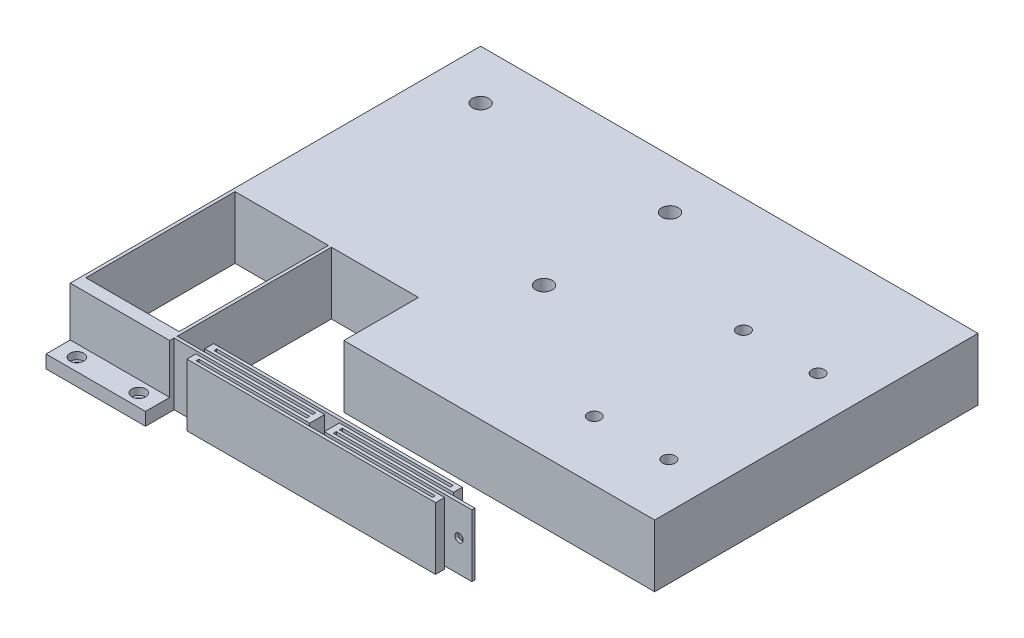
from build123d import *

# Parameters (mm, degrees)
SKETCH1_W                                      = 200
SKETCH1_H                                      = 174.75
BOSS_EXTRUDE1_DEPTH                            = 25
SKETCH2_W                                      = 40
SKETCH2_H                                      = 9.75
CUT_EXTRUDE1_DEPTH                             = 19.8
SKETCH3_W                                      = 37.5
SKETCH3_H                                      = 60
CUT_EXTRUDE2_DEPTH                             = 26
BOSS_EXTRUDE2_DEPTH                            = 25
SKETCH5_R                                      = 1.65
CUT_EXTRUDE3_DEPTH                             = 1.23
SKETCH6_R                                      = 3.325
CUT_EXTRUDE4_DEPTH                             = 26
SKETCH7_R                                      = 0.685
CUT_EXTRUDE5_DEPTH                             = 6.2
F_1_4_20_TAPPED_HOLE1_D                        = 5.1054
CBORE_FOR_4_SOCKET_HEAD_CAP_SCREW1_D           = 3.2639
CBORE_FOR_4_SOCKET_HEAD_CAP_SCREW1_CBORE_D     = 5.55752
CBORE_FOR_4_SOCKET_HEAD_CAP_SCREW1_CBORE_DEPTH = 2.8448


with BuildPart() as part:
    # Sketch1 → Boss-Extrude1 (new body)
    with BuildSketch(Plane(origin=(0, 0, 0), x_dir=(1, 0, 0), z_dir=(0, 1, 0))):
        Rectangle(SKETCH1_W, SKETCH1_H)
    extrude(amount=BOSS_EXTRUDE1_DEPTH)

    # Sketch2 → Cut-Extrude1 (cut)
    with BuildSketch(Plane(origin=(0, 25, 0), x_dir=(1, 0, 0), z_dir=(0, 1, 0))):
        with Locations((-80, -82.5)):
            Rectangle(SKETCH2_W, SKETCH2_H)
    extrude(amount=-CUT_EXTRUDE1_DEPTH, mode=Mode.SUBTRACT)

    # Sketch3 → Cut-Extrude2 (cut, through all)
    with BuildSketch(Plane(origin=(0, 25, 0), x_dir=(1, 0, 0), z_dir=(0, 1, 0))):
        with Locations((-79.98, -42.625)):
            Rectangle(SKETCH3_W, SKETCH3_H)
        Polygon((-25, -42.625), (100, -42.625), (100, -87.375), (-60, -87.375), (-60, -12.625), (-25, -12.625), align=None)
    extrude(amount=-CUT_EXTRUDE2_DEPTH, mode=Mode.SUBTRACT)

    # Sketch4 → Boss-Extrude2 (add)
    with BuildSketch(Plane(origin=(0, 25, 0), x_dir=(1, 0, 0), z_dir=(0, 1, 0))):
        Polygon((-60, -74.625), (-5.5, -74.625), (-5.5, -73.455), (-50.1, -73.455), (-50.1, -69.865), (49.9, -69.865), (49.9, -73.455), (5.2, -73.455), (5.2, -74.625), (59.7, -74.625), (59.7, -75.855), (5.2, -75.855), (5.2, -77.025), (49.9, -77.025), (49.9, -80.615), (-50.1, -80.615), (-50.1, -77.025), (-5.5, -77.025), (-5.5, -75.855), (-60, -75.855), align=None)
        Polygon((-3.1, -72.225), (-3.1, -78.255), (-47.63, -78.255), (-47.63, -79.385), (47.43, -79.385), (47.43, -78.255), (2.8, -78.255), (2.8, -72.225), (47.43, -72.225), (47.43, -71.095), (-47.63, -71.095), (-47.63, -72.225), align=None, mode=Mode.SUBTRACT)
    extrude(amount=-BOSS_EXTRUDE2_DEPTH)

    # Sketch5 → Cut-Extrude3 (cut)
    with BuildSketch(Plane.XY.offset(75.855)):
        with Locations((54.55, 12.65)):
            Circle(SKETCH5_R)
    extrude(amount=-CUT_EXTRUDE3_DEPTH, mode=Mode.SUBTRACT)

    # Sketch6 → Cut-Extrude4 (cut, through all)
    with BuildSketch(Plane(origin=(0, 25, 0), x_dir=(1, 0, 0), z_dir=(0, 1, 0))):
        with Locations((-80.175, 67.55)):
            Circle(SKETCH6_R)
        with Locations((-4.025, 67.55)):
            Circle(SKETCH6_R)
        with Locations((-4.025, 16.9)):
            Circle(SKETCH6_R)
    extrude(amount=-CUT_EXTRUDE4_DEPTH, mode=Mode.SUBTRACT)

    # Sketch7 → Cut-Extrude5 (cut, through all)
    with BuildSketch(Plane(origin=(0, 5.2, 0), x_dir=(1, 0, 0), z_dir=(0, 1, 0))):
        with Locations((-92.665, -82.29)):
            Circle(SKETCH7_R)
        with Locations((-67.795, -82.29)):
            Circle(SKETCH7_R)
    extrude(amount=-CUT_EXTRUDE5_DEPTH, mode=Mode.SUBTRACT)

    # 1/4-20 Tapped Hole1 (through all)
    with Locations(Plane(origin=(0, 25, 0), x_dir=(1, 0, 0), z_dir=(0, 1, 0))):
        with Locations((51.745235504, 41.326927492), (81.748513239, 41.326927492), (81.748513239, -18.673072418), (51.745235504, -18.673072418)):
            Hole(F_1_4_20_TAPPED_HOLE1_D / 2)

    # CBORE for #4 Socket Head Cap Screw1 (through all)
    with Locations(Plane(origin=(0, 5.2, 0), x_dir=(1, 0, 0), z_dir=(0, 1, 0))):
        with Locations((-92.665, -82.29), (-67.795, -82.29)):
            CounterBoreHole(CBORE_FOR_4_SOCKET_HEAD_CAP_SCREW1_D / 2, CBORE_FOR_4_SOCKET_HEAD_CAP_SCREW1_CBORE_D / 2, CBORE_FOR_4_SOCKET_HEAD_CAP_SCREW1_CBORE_DEPTH)


solid = part.part
